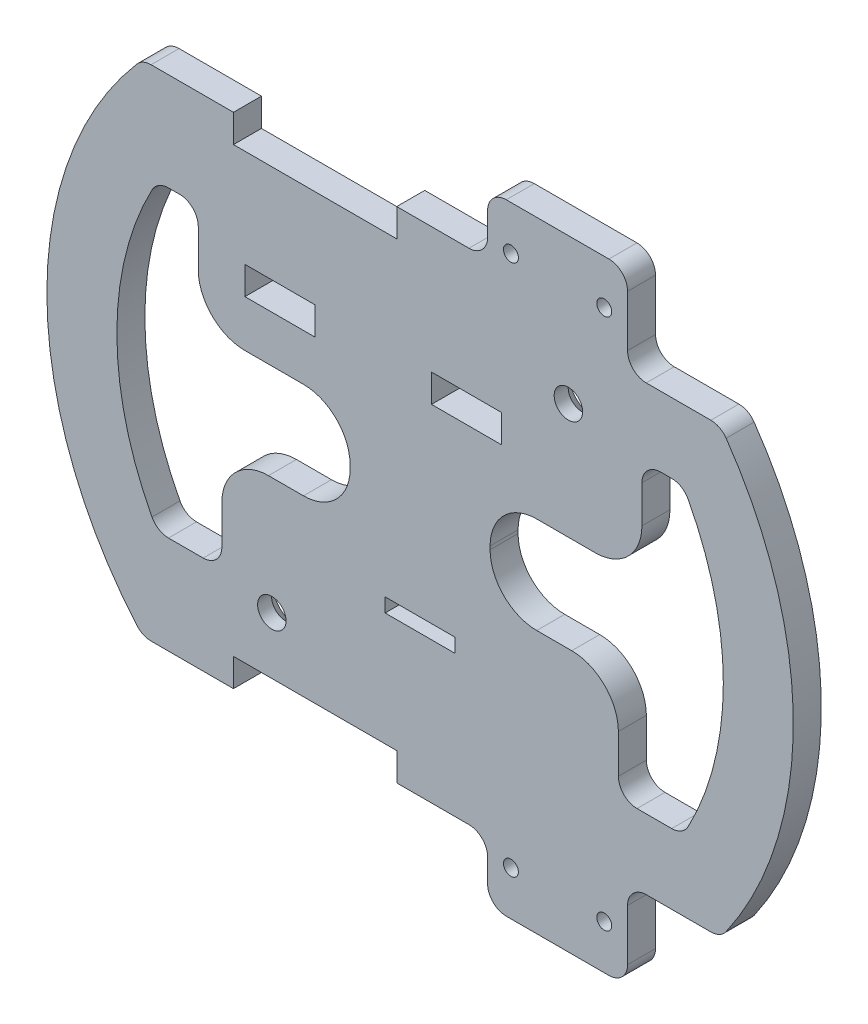
from build123d import *

# Parameters (mm, degrees)
ESBO_O1_R                = 3.05
ESBO_O1_W                = 15
ESBO_O1_H                = 3
ESBO_O1_R_2              = 1.6
ESBO_O1_H_2              = 6
RESSALTO_EXTRUS_O1_DEPTH = 6
CHANFRO1_SIZE            = 3
FILETE1_R                = 4
FILETE2_R                = 10
FILETE3_R                = 10


with BuildPart() as part:
    # Esboço1 → Ressalto-extrusão1 (new body)
    with BuildSketch(Plane.XY):
        with BuildLine():
            Line((14.471901241, -53.5), (14.471901241, -66.5))
            Line((14.471901241, -66.5), (44.471901241, -66.5))
            Line((44.471901241, -66.5), (44.471901241, -47.5))
            Line((44.471901241, -47.5), (64.371965948, -47.5))
            ThreePointArc((64.371965948, -47.5), (80, 0), (64.371965948, 47.5))
            Line((64.371965948, 47.5), (44.471901241, 47.5))
            Line((44.471901241, 47.5), (44.471901241, 66.5))
            Line((44.471901241, 66.5), (14.471901241, 66.5))
            Line((14.471901241, 66.5), (14.471901241, 53.5))
            Line((14.471901241, 53.5), (-5.003543323, 53.5))
            Line((-5.003543323, 53.5), (-5.003543323, 47.5))
            Line((-5.003543323, 47.5), (-40.003543323, 47.5))
            Line((-40.003543323, 47.5), (-40.003543323, 53.5))
            Line((-40.003543323, 53.5), (-59.478987886, 53.5))
            ThreePointArc((-59.478987886, 53.5), (-80, 0), (-59.478987886, -53.5))
            Line((-59.478987886, -53.5), (-40.003543323, -53.5))
            Line((-40.003543323, -53.5), (-40.003543323, -47.5))
            Line((-40.003543323, -47.5), (-5.003543323, -47.5))
            Line((-5.003543323, -47.5), (-5.003543323, -53.5))
            Line((-5.003543323, -53.5), (14.471901241, -53.5))
        make_face()
        with BuildLine():
            Line((-56.291651246, 32.5), (-47.55, 32.5))
            Line((-47.55, 32.5), (-47.55, 10.5))
            Line((-47.55, 10.5), (-15, 10.5))
            Line((-15, 10.5), (-15, -10.2))
            Line((-15, -10.2), (-42.5, -10.2))
            Line((-42.5, -10.2), (-42.5, -32.5))
            Line((-42.5, -32.5), (-56.291651246, -32.5))
            ThreePointArc((-56.291651246, -32.5), (-65, 0), (-56.291651246, 32.5))
        make_face(mode=Mode.SUBTRACT)
        with BuildLine():
            Line((47.55, 32.5), (56.291651246, 32.5))
            ThreePointArc((56.291651246, 32.5), (65, 0), (56.291651246, -32.5))
            Line((56.291651246, -32.5), (42.5, -32.5))
            Line((42.5, -32.5), (42.5, -10.2))
            Line((42.5, -10.2), (15, -10.2))
            Line((15, -10.2), (15, 10.5))
            Line((15, 10.5), (47.55, 10.5))
            Line((47.55, 10.5), (47.55, 32.5))
        make_face(mode=Mode.SUBTRACT)
        with Locations((-31.783703802, -35.29937921)):
            Circle(ESBO_O1_R, mode=Mode.SUBTRACT)
        with Locations((0, -21.7)):
            Rectangle(ESBO_O1_W, ESBO_O1_H, mode=Mode.SUBTRACT)
        with Locations((19.471901241, -57)):
            Circle(ESBO_O1_R_2, mode=Mode.SUBTRACT)
        with Locations((39.471901241, -57)):
            Circle(ESBO_O1_R_2, mode=Mode.SUBTRACT)
        with Locations((-30.05, 23.5)):
            Rectangle(ESBO_O1_W, ESBO_O1_H_2, mode=Mode.SUBTRACT)
        with Locations((9.95, 23.5)):
            Rectangle(ESBO_O1_W, ESBO_O1_H_2, mode=Mode.SUBTRACT)
        with Locations((31.783703802, 35.29937921)):
            Circle(ESBO_O1_R, mode=Mode.SUBTRACT)
        with Locations((19.471901241, 57)):
            Circle(ESBO_O1_R_2, mode=Mode.SUBTRACT)
        with Locations((39.471901241, 57)):
            Circle(ESBO_O1_R_2, mode=Mode.SUBTRACT)
    extrude(amount=RESSALTO_EXTRUS_O1_DEPTH)

    # Chanfro1
    chanfro1_edges = [part.edges().sort_by_distance(p)[0] for p in [
        (-34.833703802, -35.29937921, 0),
        (28.733703802, 35.29937921, 0),
    ]]
    chamfer(chanfro1_edges, length=CHANFRO1_SIZE)

    # Filete1
    filete1_edges = [part.edges().sort_by_distance(p)[0] for p in [
        (-42.5, -32.5, 3),
        (-47.55, 32.5, 3),
        (-56.291651246, 32.5, 3),
        (-56.291651246, -32.5, 3),
        (56.291651246, 32.5, 3),
        (47.55, 32.5, 3),
        (42.5, -32.5, 3),
        (56.291651246, -32.5, 3),
        (44.471901241, -47.5, 3),
        (44.471901241, -66.5, 3),
        (14.471901241, -66.5, 3),
        (14.471901241, -53.5, 3),
        (-59.478987886, -53.5, 3),
        (-59.478987886, 53.5, 3),
        (14.471901241, 53.5, 3),
        (14.471901241, 66.5, 3),
        (44.471901241, 66.5, 3),
        (44.471901241, 47.5, 3),
        (64.371965948, 47.5, 3),
        (64.371965948, -47.5, 3),
    ]]
    fillet(filete1_edges, radius=FILETE1_R)

    # Filete2
    filete2_edges = [part.edges().sort_by_distance(p)[0] for p in [
        (-15, -10.2, 3),
        (-15, 10.5, 3),
        (15, 10.5, 3),
        (15, -10.2, 3),
    ]]
    fillet(filete2_edges, radius=FILETE2_R)

    # Filete3
    filete3_edges = [part.edges().sort_by_distance(p)[0] for p in [
        (-42.5, -10.2, 3),
        (-47.55, 10.5, 3),
        (47.55, 10.5, 3),
        (42.5, -10.2, 3),
    ]]
    fillet(filete3_edges, radius=FILETE3_R)


solid = part.part
